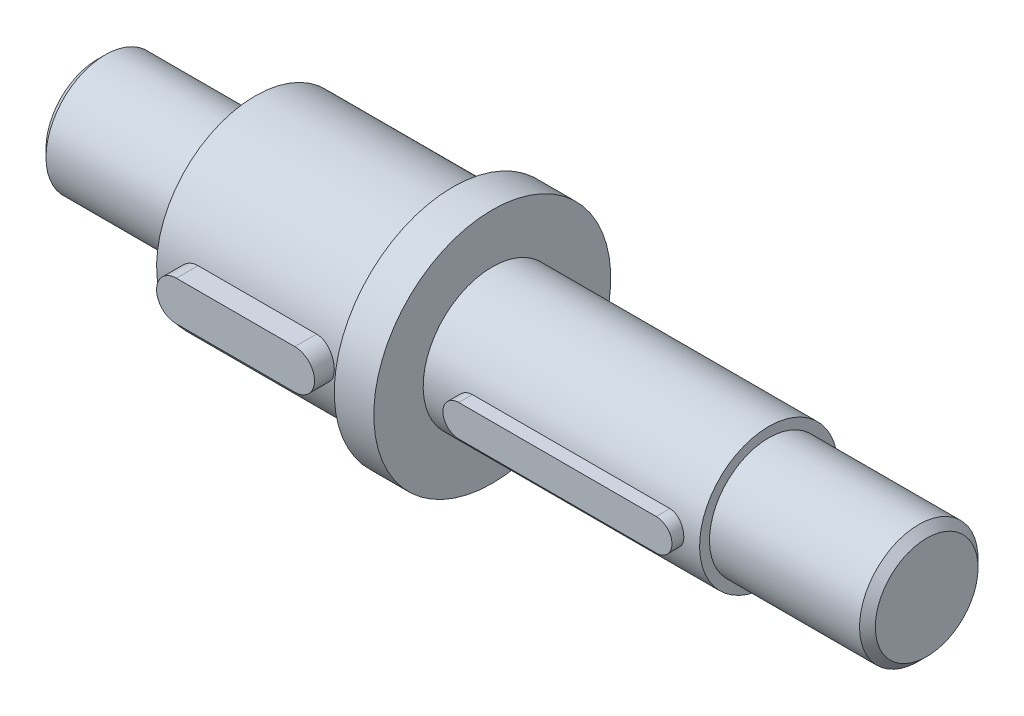
from build123d import *

# Parameters (mm, degrees)
CHAMFER1_SIZE       = 2
CHAMFER2_SIZE       = 2
CUT_EXTRUDE1_DEPTH  = 3
CUT_EXTRUDE2_DEPTH  = 5
BOSS_EXTRUDE2_DEPTH = 6
BOSS_EXTRUDE3_DEPTH = 10


with BuildPart() as part:
    # Sketch1 → Revolve1 (revolve)
    with BuildSketch(Plane.XY):
        Polygon((0, 0), (0, 15), (40, 15), (40, 25), (90, 25), (90, 30), (100, 30), (100, 17.5), (170, 17.5), (170, 15), (210, 15), (210, 0), align=None)
    revolve(axis=Axis((210, 0, 0), (-1, 0, 0)))

    # Chamfer1
    chamfer1_edges = [part.edges().sort_by_distance(p)[0] for p in [
        (0, -15, 0),
    ]]
    chamfer(chamfer1_edges, length=CHAMFER1_SIZE)

    # Chamfer2
    chamfer2_edges = [part.edges().sort_by_distance(p)[0] for p in [
        (210, -15, 0),
    ]]
    chamfer(chamfer2_edges, length=CHAMFER2_SIZE)

    # Sketch2 → Cut-Extrude1 (cut)
    with BuildSketch(Plane.XY.offset(17.5)):
        with BuildLine():
            Line((112, -4), (162, -4))
            ThreePointArc((162, -4), (166, 0), (162, 4))
            Line((162, 4), (112, 4))
            ThreePointArc((112, 4), (108, 0), (112, -4))
        make_face()
    extrude(amount=-CUT_EXTRUDE1_DEPTH, mode=Mode.SUBTRACT)

    # Sketch8 → Cut-Extrude2 (cut)
    with BuildSketch(Plane.XY.offset(25)):
        with BuildLine():
            Line((50, -5), (80, -5))
            ThreePointArc((80, -5), (85, 0), (80, 5))
            Line((80, 5), (50, 5))
            ThreePointArc((50, 5), (45, 0), (50, -5))
        make_face()
    extrude(amount=-CUT_EXTRUDE2_DEPTH, mode=Mode.SUBTRACT)

    # Sketch12 → Boss-Extrude3 (add)
    with BuildSketch(Plane.XY.offset(20)):
        with BuildLine():
            Line((50, -5), (80, -5))
            ThreePointArc((80, -5), (85, 0), (80, 5))
            Line((80, 5), (50, 5))
            ThreePointArc((50, 5), (45, 0), (50, -5))
        make_face()
    extrude(amount=BOSS_EXTRUDE3_DEPTH)


with BuildPart() as body_2:
    # Sketch11 → Boss-Extrude2 (new body)
    with BuildSketch(Plane.XY.offset(14.5)):
        with BuildLine():
            Line((112, -4), (162, -4))
            ThreePointArc((162, -4), (166, 0), (162, 4))
            Line((162, 4), (112, 4))
            ThreePointArc((112, 4), (108, 0), (112, -4))
        make_face()
    extrude(amount=BOSS_EXTRUDE2_DEPTH)


solid = Compound([part.part, body_2.part])
